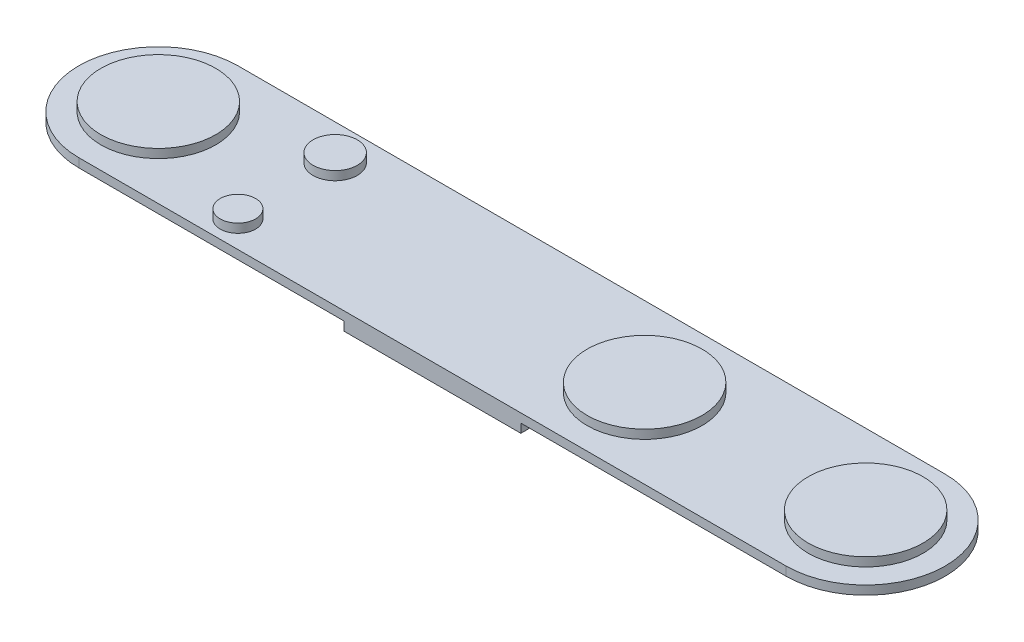
from build123d import *

# Parameters (mm, degrees)
RESSALTO_EXTRUS_O1_DEPTH = 1
ESBO_O2_R                = 2.5
ESBO_O2_R_2              = 2
ESBO_O2_R_3              = 6.5
RESSALTO_EXTRUS_O2_DEPTH = 1
ESBO_O3_W                = 20
ESBO_O3_H                = 18
RESSALTO_EXTRUS_O3_DEPTH = 1


with BuildPart() as part:
    # Esboço1 → Ressalto-extrusão1 (new body)
    with BuildSketch(Plane(origin=(0, 0, 0), x_dir=(1, 0, 0), z_dir=(0, 1, 0))):
        with BuildLine():
            Line((-40, 9), (40, 9))
            ThreePointArc((40, 9), (49, 0), (40, -9))
            Line((40, -9), (-40, -9))
            ThreePointArc((-40, -9), (-49, 0), (-40, 9))
        make_face()
    extrude(amount=RESSALTO_EXTRUS_O1_DEPTH)

    # Esboço2 → Ressalto-extrusão2 (add)
    with BuildSketch(Plane(origin=(0, 1, 0), x_dir=(1, 0, 0), z_dir=(0, 1, 0))):
        with Locations((-25, 5)):
            Circle(ESBO_O2_R)
        with Locations((-25, -6)):
            Circle(ESBO_O2_R_2)
        with Locations((15, 0)):
            Circle(ESBO_O2_R_3)
        with Locations((40, 0)):
            Circle(ESBO_O2_R_3)
        with Locations((-40, 0)):
            Circle(ESBO_O2_R_3)
    extrude(amount=RESSALTO_EXTRUS_O2_DEPTH)

    # Esboço3 → Ressalto-extrusão3 (add)
    with BuildSketch(Plane.XZ):
        Rectangle(ESBO_O3_W, ESBO_O3_H)
    extrude(amount=RESSALTO_EXTRUS_O3_DEPTH)


solid = part.part
